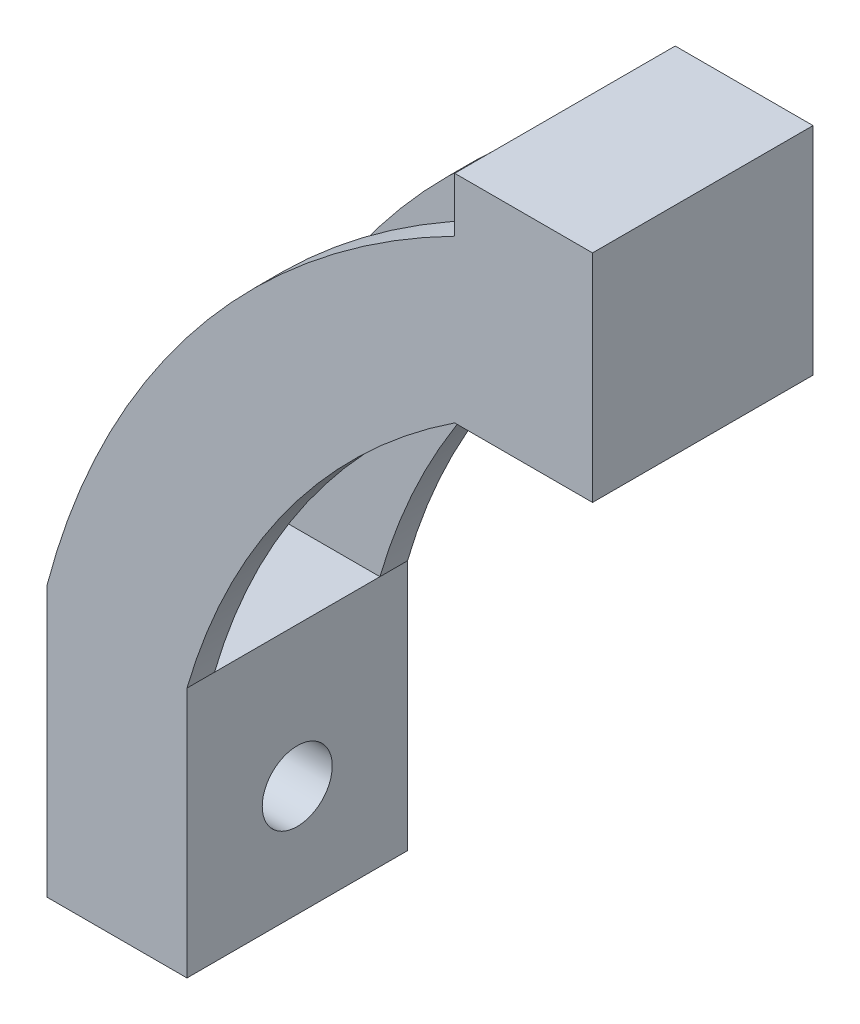
from build123d import *

# Parameters (mm, degrees)
SKETCH3_W                = 40
SKETCH3_H                = 45.541401669
BOSS_EXTRUDE2_DEPTH      = 300
BOSS_EXTRUDE2_DEPTH_BACK = 300
BOSS_EXTRUDE1_DEPTH      = 20
BOSS_EXTRUDE1_DEPTH_BACK = 20
CUT_EXTRUDE1_DEPTH       = 21
CUT_EXTRUDE1_DEPTH_BACK  = 21
SKETCH6_R                = 6.35
CUT_EXTRUDE3_DEPTH       = 464.230235913
SKETCH7_W                = 30
SKETCH7_H                = 500
CUT_EXTRUDE4_DEPTH       = 301
SKETCH9_W                = 717.699329224
SKETCH9_H                = 847.048890614
CUT_EXTRUDE6_DEPTH       = 21
CUT_EXTRUDE6_DEPTH_BACK  = 21
BOSS_EXTRUDE4_START      = -20
SKETCH11_W               = 25
SKETCH11_H               = 39.2080494
BOSS_EXTRUDE4_DEPTH      = 40
SKETCH15_W               = 300
SKETCH15_H               = 135
CUT_EXTRUDE9_DEPTH       = 21
CUT_EXTRUDE9_DEPTH_BACK  = 21


with BuildPart() as part:
    # Sketch3 → Boss-Extrude2 (new body, two sides)
    with BuildSketch(Plane(origin=(0, 0, 0), x_dir=(0, 0, -1), z_dir=(1, 0, 0))) as boss_extrude2_sk:
        with Locations((0, 10.070700834)):
            Rectangle(SKETCH3_W, SKETCH3_H)
    extrude(amount=BOSS_EXTRUDE2_DEPTH)
    extrude(boss_extrude2_sk.sketch, amount=-BOSS_EXTRUDE2_DEPTH_BACK)

    # Sketch2 → Boss-Extrude1 (add, two sides)
    with BuildSketch(Plane.XY) as boss_extrude1_sk:
        with BuildLine():
            Line((105.595237536, 0), (-143.695237536, 0))
            ThreePointArc((-143.695237536, 0), (0, 143.695237536), (143.695237536, 0))
            Line((143.695237536, 0), (105.595237536, 0))
        make_face()
    extrude(amount=BOSS_EXTRUDE1_DEPTH)
    extrude(boss_extrude1_sk.sketch, amount=-BOSS_EXTRUDE1_DEPTH_BACK)

    # Sketch4 → Cut-Extrude1 (cut, two sides)
    with BuildSketch(Plane.XY) as cut_extrude1_sk:
        with BuildLine():
            Line((113.645085948, 32.841401669), (113.645085948, -47.609700579))
            Line((113.645085948, -47.609700579), (-113.645085948, -47.609700579))
            Line((-113.645085948, -47.609700579), (-113.645085948, 32.841401669))
            ThreePointArc((-113.645085948, 32.841401669), (0, 118.295237536), (113.645085948, 32.841401669))
        make_face()
    extrude(amount=CUT_EXTRUDE1_DEPTH, mode=Mode.SUBTRACT)
    extrude(cut_extrude1_sk.sketch, amount=-CUT_EXTRUDE1_DEPTH_BACK, mode=Mode.SUBTRACT)

    # Sketch6 → Cut-Extrude3 (cut, through all)
    with BuildSketch(Plane.ZY.offset(163.230235913)):
        with Locations((0, 7.441401669)):
            Circle(SKETCH6_R)
    extrude(amount=-CUT_EXTRUDE3_DEPTH, mode=Mode.SUBTRACT)

    # Sketch7 → Cut-Extrude4 (cut, through all)
    with BuildSketch(Plane(origin=(0, 0, 0), x_dir=(0, 0, -1), z_dir=(1, 0, 0))):
        with Locations((0, 282.841401669)):
            Rectangle(SKETCH7_W, SKETCH7_H)
    extrude(amount=-CUT_EXTRUDE4_DEPTH, mode=Mode.SUBTRACT)

    # Sketch9 → Cut-Extrude6 (cut, two sides)
    with BuildSketch(Plane.XY) as cut_extrude6_sk:
        with Locations((318.769664612, 189.175554693)):
            Rectangle(SKETCH9_W, SKETCH9_H)
    extrude(amount=CUT_EXTRUDE6_DEPTH, mode=Mode.SUBTRACT)
    extrude(cut_extrude6_sk.sketch, amount=-CUT_EXTRUDE6_DEPTH_BACK, mode=Mode.SUBTRACT)

    # Sketch11 → Boss-Extrude4 (add)
    with BuildSketch(Plane.XY.offset(BOSS_EXTRUDE4_START)):
        with Locations((-52.58, 118.388420349)):
            Rectangle(SKETCH11_W, SKETCH11_H)
    extrude(amount=BOSS_EXTRUDE4_DEPTH)

    # Sketch15 → Cut-Extrude9 (cut, two sides)
    with BuildSketch(Plane.XY) as cut_extrude9_sk:
        with Locations((-289.045085948, 35.220701391)):
            Rectangle(SKETCH15_W, SKETCH15_H)
    extrude(amount=CUT_EXTRUDE9_DEPTH, mode=Mode.SUBTRACT)
    extrude(cut_extrude9_sk.sketch, amount=-CUT_EXTRUDE9_DEPTH_BACK, mode=Mode.SUBTRACT)


solid = part.part
